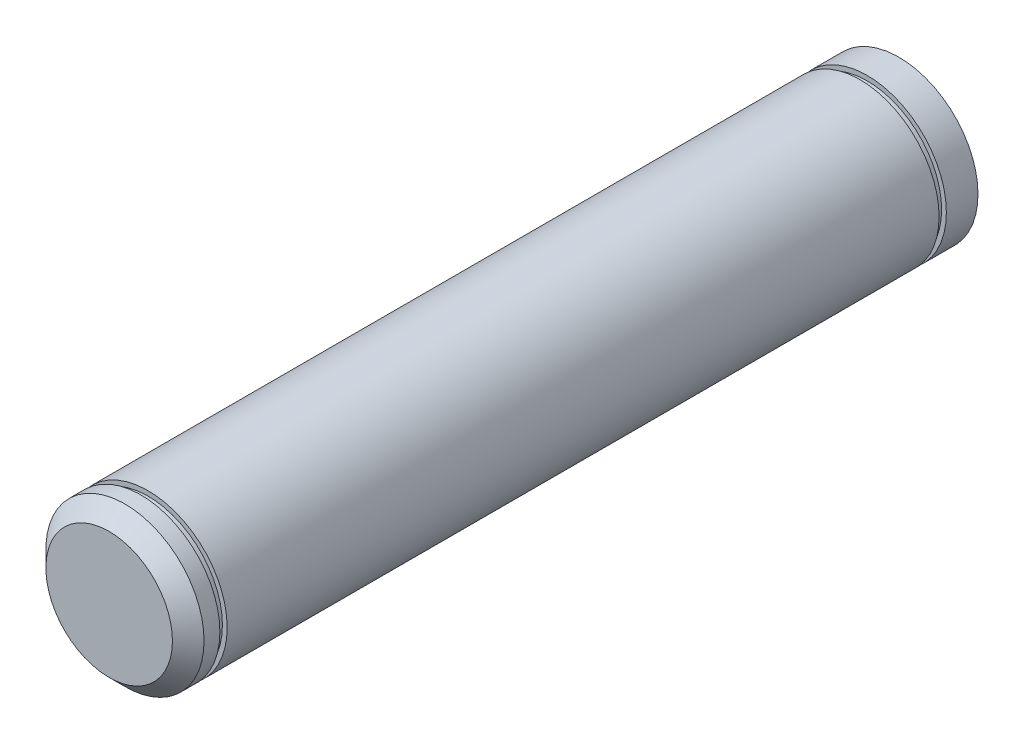
from build123d import *

# Parameters (mm, degrees)
SKETCH3_R           = 12.7
BOSS_EXTRUDE1_DEPTH = 304.8
CHAMFER1_SIZE       = 2.54
CUT_EXTRUDE1_START  = -126.799999892
SKETCH4_R           = 12.7
CUT_EXTRUDE1_DEPTH  = 483.800000108
CUT_EXTRUDE2_START  = -5.08
SKETCH5_R           = 12.7
SKETCH5_R_2         = 11.938
CUT_EXTRUDE2_DEPTH  = 1.1684


with BuildPart() as part:
    # Sketch3 → Boss-Extrude1 (new body, symmetric)
    with BuildSketch(Plane.XY):
        Circle(SKETCH3_R)
    extrude(amount=BOSS_EXTRUDE1_DEPTH, both=True)

    # Chamfer1
    chamfer1_edges = [part.edges().sort_by_distance(p)[0] for p in [
        (-12.7, 0, -304.8),
        (-12.7, 0, 304.8),
    ]]
    chamfer(chamfer1_edges, length=CHAMFER1_SIZE)

    # Sketch4 → Cut-Extrude1 (cut, through all)
    with BuildSketch(Plane.XY.offset(304.8).offset(CUT_EXTRUDE1_START)):
        Circle(SKETCH4_R)
    extrude(amount=-CUT_EXTRUDE1_DEPTH, mode=Mode.SUBTRACT)

    # Sketch5 → Cut-Extrude2 (cut)
    with BuildSketch(Plane.XY.offset(304.8).offset(CUT_EXTRUDE2_START)):
        Circle(SKETCH5_R)
        Circle(SKETCH5_R_2, mode=Mode.SUBTRACT)
    cut_extrude2 = extrude(amount=-CUT_EXTRUDE2_DEPTH, mode=Mode.SUBTRACT)

    # Mirror3: Cut-Extrude2 across plane
    add(cut_extrude2.mirror(Plane.XY.offset(241.400000054)), mode=Mode.SUBTRACT)


solid = part.part
